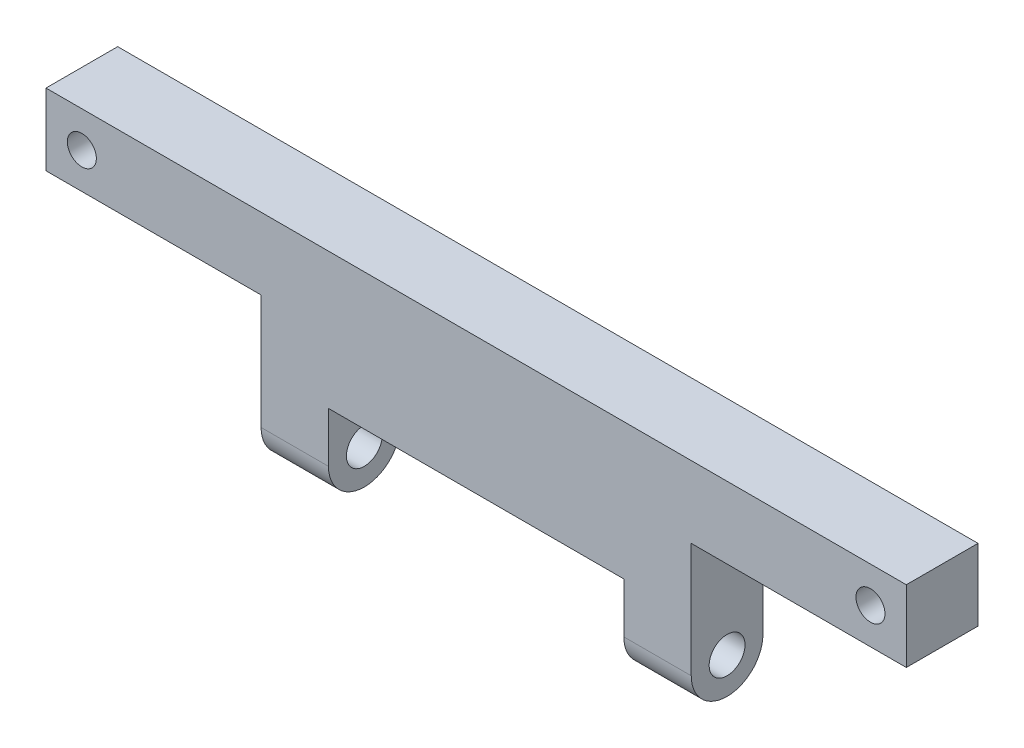
from build123d import *

# Parameters (mm, degrees)
SKETCH1_W           = 20
SKETCH1_H           = 60
BOSS_EXTRUDE1_DEPTH = 5
SKETCH2_R           = 2.5
SKETCH2_R_2         = 1.25
BOSS_EXTRUDE2_DEPTH = 20
SKETCH3_R           = 1.25
CUT_EXTRUDE1_DEPTH  = 29
SKETCH4_R           = 2.5
SKETCH4_R_2         = 1.25
BOSS_EXTRUDE3_DEPTH = 20
SKETCH5_R           = 1.25
CUT_EXTRUDE2_DEPTH  = 29
SKETCH6_R           = 1.25
BOSS_EXTRUDE4_DEPTH = 30
SKETCH7_W           = 20.6
SKETCH7_H           = 7
CUT_EXTRUDE3_DEPTH  = 30
SKETCH8_W           = 60.511546569
SKETCH8_H           = 78.563917263
CUT_EXTRUDE4_DEPTH  = 41
SKETCH10_W          = 60
SKETCH10_H          = 5
BOSS_EXTRUDE5_DEPTH = 5
SKETCH11_R          = 1.012314422
CUT_EXTRUDE5_DEPTH  = 41


with BuildPart() as part:
    # Sketch1 → Boss-Extrude1 (new body)
    with BuildSketch(Plane.XY):
        with Locations((10, 30)):
            Rectangle(SKETCH1_W, SKETCH1_H)
    extrude(amount=BOSS_EXTRUDE1_DEPTH)

    # Sketch2 → Boss-Extrude2 (add)
    with BuildSketch(Plane(origin=(20, 0, 0), x_dir=(0, 0, -1), z_dir=(1, 0, 0))):
        with Locations((-2.5, 60)):
            Circle(SKETCH2_R)
        with Locations((-2.5, 60)):
            Circle(SKETCH2_R_2, mode=Mode.SUBTRACT)
    extrude(amount=-BOSS_EXTRUDE2_DEPTH)

    # Sketch3 → Cut-Extrude1 (cut)
    with BuildSketch(Plane.ZY):
        with Locations(Location((2.5, 60, 0), (0, 0, 180))):
            Circle(SKETCH3_R)
    extrude(amount=-CUT_EXTRUDE1_DEPTH, mode=Mode.SUBTRACT)

    # Sketch4 → Boss-Extrude3 (add)
    with BuildSketch(Plane.ZY):
        with Locations((2.5, 0)):
            Circle(SKETCH4_R)
        with Locations((2.5, 0)):
            Circle(SKETCH4_R_2, mode=Mode.SUBTRACT)
    extrude(amount=-BOSS_EXTRUDE3_DEPTH)

    # Sketch5 → Cut-Extrude2 (cut)
    with BuildSketch(Plane(origin=(20, 0, 0), x_dir=(0, 0, -1), z_dir=(1, 0, 0))):
        with Locations(Location((-2.5, 0, 0), (0, 0, 180))):
            Circle(SKETCH5_R)
    extrude(amount=-CUT_EXTRUDE2_DEPTH, mode=Mode.SUBTRACT)

    # Sketch6 → Boss-Extrude4 (add)
    with BuildSketch(Plane.ZY):
        with BuildLine():
            Line((5, 60), (5, 70))
            Line((5, 70), (0, 70))
            Line((0, 70), (0, 60))
            ThreePointArc((0, 60), (2.5, 57.5), (5, 60))
        make_face()
        with Locations(Location((2.5, 60, 0), (0, 0, 180))):
            Circle(SKETCH6_R, mode=Mode.SUBTRACT)
    extrude(amount=BOSS_EXTRUDE4_DEPTH)

    # Sketch7 → Cut-Extrude3 (cut)
    with BuildSketch(Plane(origin=(0, 0, 0), x_dir=(-1, 0, 0), z_dir=(0, 0, -1))):
        with Locations((15, 60)):
            Rectangle(SKETCH7_W, SKETCH7_H)
    extrude(amount=-CUT_EXTRUDE3_DEPTH, mode=Mode.SUBTRACT)

    # Sketch8 → Cut-Extrude4 (cut)
    with BuildSketch(Plane.ZY):
        with Locations((2.066743104, 31.078249137)):
            Rectangle(SKETCH8_W, SKETCH8_H)
    extrude(amount=-CUT_EXTRUDE4_DEPTH, mode=Mode.SUBTRACT)

    # Sketch10 → Boss-Extrude5 (add)
    with BuildSketch(Plane(origin=(0, 0, 0), x_dir=(-1, 0, 0), z_dir=(0, 0, -1))):
        with Locations((15, 70.5)):
            Rectangle(SKETCH10_W, SKETCH10_H)
    extrude(amount=-BOSS_EXTRUDE5_DEPTH)

    # Sketch11 → Cut-Extrude5 (cut)
    with BuildSketch(Plane(origin=(0, 0, 0), x_dir=(-1, 0, 0), z_dir=(0, 0, -1))):
        with Locations(Location((-12.5, 70.5, 0), (0, 0, 90))):
            Circle(SKETCH11_R)
        with Locations(Location((42.5, 70.5, 0), (0, 0, 90))):
            Circle(SKETCH11_R)
    extrude(amount=-CUT_EXTRUDE5_DEPTH, mode=Mode.SUBTRACT)


solid = part.part
